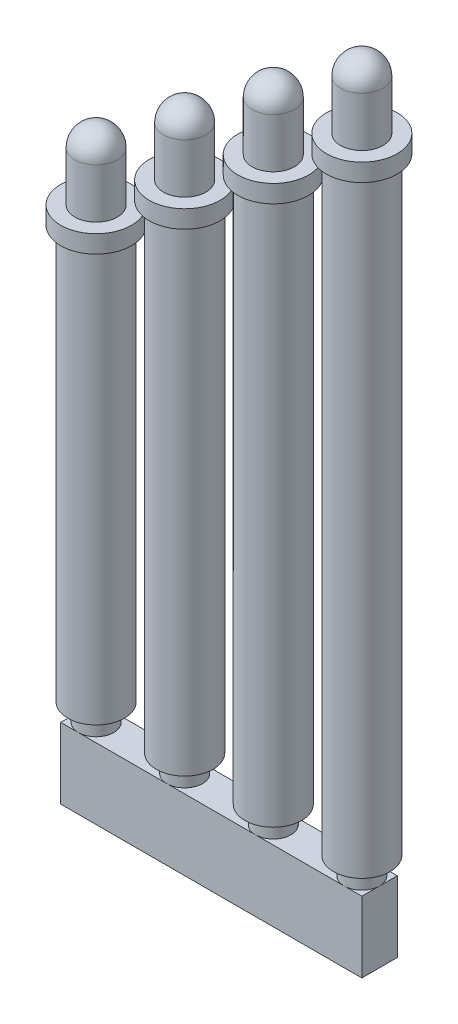
from build123d import *

# Parameters (mm, degrees)
FILLET2_R           = 0.6
FILLET3_R           = 0.6
FILLET4_R           = 0.6
FILLET5_R           = 0.6
SKETCH14_W          = 8.5
SKETCH14_H          = 1
BOSS_EXTRUDE1_DEPTH = 2


with BuildPart() as part:
    # Sketch10 → Revolve1 (revolve)
    with BuildSketch(Plane.XY):
        Polygon((0, 0), (-0.5, 0), (-0.5, 0.5), (-0.8, 0.5), (-0.8, 12.15), (-1, 12.15), (-1, 12.65), (-0.6, 12.65), (-0.6, 14.65), (0, 14.65), align=None)
    revolve(axis=Axis((0, 14.65, 0), (0, -1, 0)))

    # Fillet2
    fillet2_edges = [part.edges().sort_by_distance(p)[0] for p in [
        (0.6, 14.65, 0),
    ]]
    fillet(fillet2_edges, radius=FILLET2_R)



with BuildPart() as body_2:
    # Sketch11 → Revolve2 (revolve)
    with BuildSketch(Plane.XY):
        Polygon((2.5, 0), (2, 0), (2, 0.5), (1.7, 0.5), (1.7, 14.01), (1.5, 14.01), (1.5, 14.51), (1.9, 14.51), (1.9, 16.51), (2.5, 16.51), align=None)
    revolve(axis=Axis((2.5, 16.51, 0), (0, -1, 0)))

    # Fillet3
    fillet3_edges = [body_2.edges().sort_by_distance(p)[0] for p in [
        (3.1, 16.51, 0),
    ]]
    fillet(fillet3_edges, radius=FILLET3_R)


with BuildPart() as body_3:
    # Sketch12 → Revolve3 (revolve)
    with BuildSketch(Plane.XY):
        Polygon((5, 0), (4.5, 0), (4.5, 0.5), (4.2, 0.5), (4.2, 15.88), (4, 15.88), (4, 16.38), (4.4, 16.38), (4.4, 18.38), (5, 18.38), align=None)
    revolve(axis=Axis((5, 18.38, 0), (0, -1, 0)))

    # Fillet4
    fillet4_edges = [body_3.edges().sort_by_distance(p)[0] for p in [
        (5.6, 18.38, 0),
    ]]
    fillet(fillet4_edges, radius=FILLET4_R)


with BuildPart() as body_4:
    # Sketch13 → Revolve4 (revolve)
    with BuildSketch(Plane.XY):
        Polygon((7.5, 0), (7, 0), (7, 0.5), (6.7, 0.5), (6.7, 17.65), (6.5, 17.65), (6.5, 18.15), (6.9, 18.15), (6.9, 20.15), (7.5, 20.15), align=None)
    revolve(axis=Axis((7.5, 20.15, 0), (0, -1, 0)))

    # Fillet5
    fillet5_edges = [body_4.edges().sort_by_distance(p)[0] for p in [
        (8.1, 20.15, 0),
    ]]
    fillet(fillet5_edges, radius=FILLET5_R)


with BuildPart() as part_1:
    add(part.part)

    add(body_2.part)  # Boss-Extrude1 merges body 2

    add(body_3.part)  # Boss-Extrude1 merges body 3

    add(body_4.part)  # Boss-Extrude1 merges body 4
    # Sketch14 → Boss-Extrude1 (add)
    with BuildSketch(Plane.XZ):
        with Locations((3.75, 0)):
            Rectangle(SKETCH14_W, SKETCH14_H)
    extrude(amount=BOSS_EXTRUDE1_DEPTH)


solid = part_1.part
